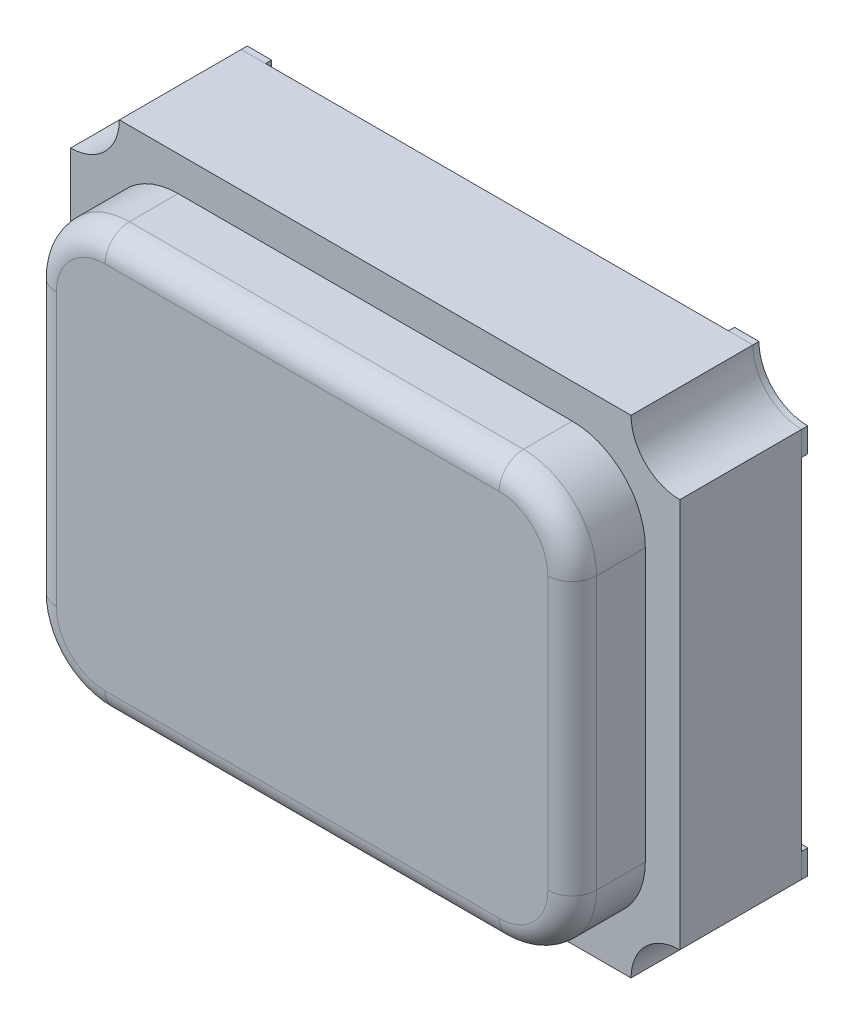
from build123d import *

# Parameters (mm, degrees)
SKETCH1_W             = 2.5
SKETCH1_H             = 2
BOSS_EXTRUDE1_DEPTH   = 0.5
SKETCH2_R             = 0.2
CUT_EXTRUDE1_DEPTH    = 0.5
BOSS_EXTRUDE2_DEPTH   = 0.3
BOSS_EXTRUDE3_DEPTH   = 0.025
BOSS_EXTRUDE3_2_DEPTH = 0.025
BOSS_EXTRUDE3_3_DEPTH = 0.025
BOSS_EXTRUDE3_4_DEPTH = 0.025
FILLET1_R             = 0.1


with BuildPart() as part:
    # Sketch1 → Boss-Extrude1 (new body)
    with BuildSketch(Plane.XY):
        Rectangle(SKETCH1_W, SKETCH1_H)
    extrude(amount=BOSS_EXTRUDE1_DEPTH)

    # Sketch2 → Cut-Extrude1 (cut)
    with BuildSketch(Plane.XY.offset(0.5)):
        with Locations((-1.25, 1)):
            Circle(SKETCH2_R)
        with Locations((1.25, 1)):
            Circle(SKETCH2_R)
        with Locations((-1.25, -1)):
            Circle(SKETCH2_R)
        with Locations((1.25, -1)):
            Circle(SKETCH2_R)
    extrude(amount=-CUT_EXTRUDE1_DEPTH, mode=Mode.SUBTRACT)

    # Sketch3 → Boss-Extrude2 (add)
    with BuildSketch(Plane.XY.offset(0.5)):
        with BuildLine():
            Line((-1.108578644, 0.558578644), (-1.108578644, -0.558578644))
            ThreePointArc((-1.108578644, -0.558578644), (-1.020710678, -0.770710678), (-0.808578644, -0.858578644))
            Line((-0.808578644, -0.858578644), (0.808578644, -0.858578644))
            ThreePointArc((0.808578644, -0.858578644), (1.020710678, -0.770710678), (1.108578644, -0.558578644))
            Line((1.108578644, -0.558578644), (1.108578644, 0.558578644))
            ThreePointArc((1.108578644, 0.558578644), (1.020710678, 0.770710678), (0.808578644, 0.858578644))
            Line((0.808578644, 0.858578644), (-0.808578644, 0.858578644))
            ThreePointArc((-0.808578644, 0.858578644), (-1.020710678, 0.770710678), (-1.108578644, 0.558578644))
        make_face()
    extrude(amount=BOSS_EXTRUDE2_DEPTH)

    # Fillet1
    fillet1_edges = [part.edges().sort_by_distance(p)[0] for p in [
        (-1.020710678, -0.770710678, 0.8),
        (0, -0.858578644, 0.8),
        (1.020710678, -0.770710678, 0.8),
        (1.108578644, 0, 0.8),
        (1.020710678, 0.770710678, 0.8),
        (0, 0.858578644, 0.8),
        (-1.020710678, 0.770710678, 0.8),
        (-1.108578644, 0, 0.8),
    ]]
    fillet(fillet1_edges, radius=FILLET1_R)


with BuildPart() as body_2:
    # Sketch4 → Boss-Extrude3 (new body)
    with BuildSketch(Plane(origin=(0, 0, 0), x_dir=(-1, 0, 0), z_dir=(0, 0, -1))):
        with BuildLine():
            Line((0.45, -0.3), (0.3, -0.45))
            Line((0.3, -0.45), (0.3, -0.9))
            Line((0.3, -0.9), (0.95, -0.9))
            Line((0.95, -0.9), (0.95, -1))
            Line((0.95, -1), (1.05, -1))
            ThreePointArc((1.05, -1), (1.108578644, -0.858578644), (1.25, -0.8))
            Line((1.25, -0.8), (1.25, -0.7))
            Line((1.25, -0.7), (1.15, -0.7))
            Line((1.15, -0.7), (1.15, -0.3))
            Line((1.15, -0.3), (0.45, -0.3))
        make_face()
    extrude(amount=BOSS_EXTRUDE3_DEPTH)


with BuildPart() as body_3:
    # Sketch4 → Boss-Extrude3 2 (new body)
    with BuildSketch(Plane(origin=(0, 0, 0), x_dir=(-1, 0, 0), z_dir=(0, 0, -1))):
        with BuildLine():
            Line((-0.95, 0.9), (-0.3, 0.9))
            Line((-0.3, 0.9), (-0.3, 0.3))
            Line((-0.3, 0.3), (-1.15, 0.3))
            Line((-1.15, 0.3), (-1.15, 0.7))
            Line((-1.15, 0.7), (-1.25, 0.7))
            Line((-1.25, 0.7), (-1.25, 0.8))
            ThreePointArc((-1.25, 0.8), (-1.108578644, 0.858578644), (-1.05, 1))
            Line((-1.05, 1), (-0.95, 1))
            Line((-0.95, 1), (-0.95, 0.9))
        make_face()
    extrude(amount=BOSS_EXTRUDE3_2_DEPTH)


with BuildPart() as body_4:
    # Sketch4 → Boss-Extrude3 3 (new body)
    with BuildSketch(Plane(origin=(0, 0, 0), x_dir=(-1, 0, 0), z_dir=(0, 0, -1))):
        with BuildLine():
            Line((0.95, 1), (0.95, 0.9))
            Line((0.95, 0.9), (0.3, 0.9))
            Line((0.3, 0.9), (0.3, 0.3))
            Line((0.3, 0.3), (1.15, 0.3))
            Line((1.15, 0.3), (1.15, 0.7))
            Line((1.15, 0.7), (1.25, 0.7))
            Line((1.25, 0.7), (1.25, 0.8))
            ThreePointArc((1.25, 0.8), (1.108578644, 0.858578644), (1.05, 1))
            Line((1.05, 1), (0.95, 1))
        make_face()
    extrude(amount=BOSS_EXTRUDE3_3_DEPTH)


with BuildPart() as body_5:
    # Sketch4 → Boss-Extrude3 4 (new body)
    with BuildSketch(Plane(origin=(0, 0, 0), x_dir=(-1, 0, 0), z_dir=(0, 0, -1))):
        with BuildLine():
            Line((-0.95, -1), (-0.95, -0.9))
            Line((-0.95, -0.9), (-0.3, -0.9))
            Line((-0.3, -0.9), (-0.3, -0.3))
            Line((-0.3, -0.3), (-1.15, -0.3))
            Line((-1.15, -0.3), (-1.15, -0.7))
            Line((-1.15, -0.7), (-1.25, -0.7))
            Line((-1.25, -0.7), (-1.25, -0.8))
            ThreePointArc((-1.25, -0.8), (-1.108578644, -0.858578644), (-1.05, -1))
            Line((-1.05, -1), (-0.95, -1))
        make_face()
    extrude(amount=BOSS_EXTRUDE3_4_DEPTH)


solid = Compound([part.part, body_2.part, body_3.part, body_4.part, body_5.part])
